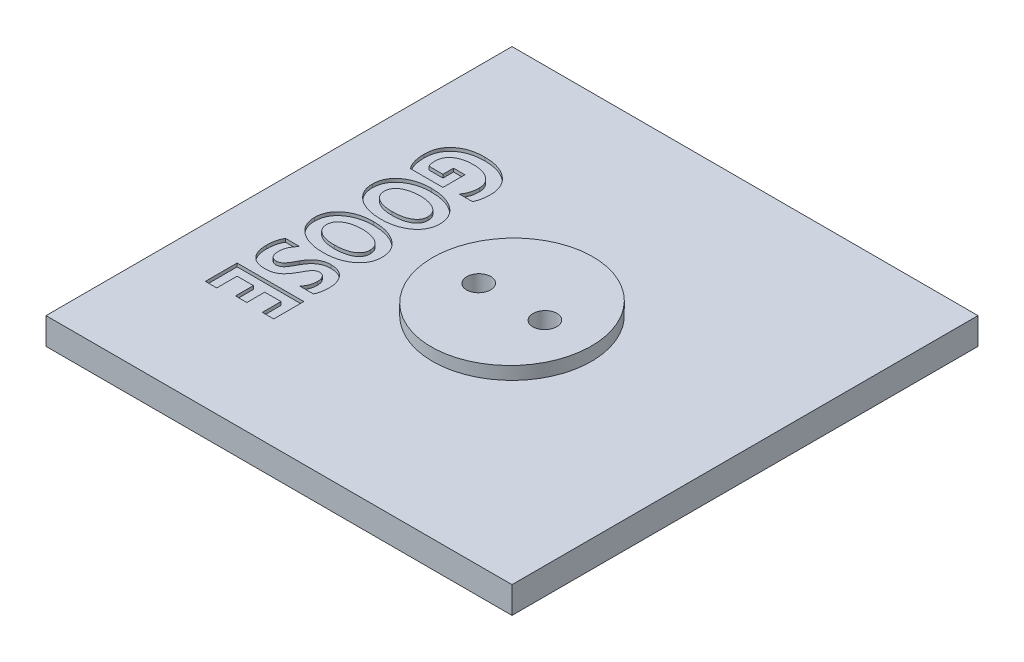
from build123d import *

# Parameters (mm, degrees)
SKETCH1_W           = 69.85
SKETCH1_H           = 69.85
BOSS_EXTRUDE1_DEPTH = 4
SKETCH2_R           = 11.90625
BOSS_EXTRUDE2_DEPTH = 2
CUT_EXTRUDE2_DEPTH  = 70.85
CUT_EXTRUDE1_REACH  = 8.401
SKETCH3_R           = 1.7859375
CUT_EXTRUDE3_DEPTH  = 0.5


with BuildPart() as part:
    # Sketch1 → Boss-Extrude1 (new body)
    with BuildSketch(Plane(origin=(0, 0, 0), x_dir=(1, 0, 0), z_dir=(0, 1, 0))):
        with Locations((34.925, 34.925)):
            Rectangle(SKETCH1_W, SKETCH1_H)
    extrude(amount=BOSS_EXTRUDE1_DEPTH)

    # Sketch2 → Boss-Extrude2 (add)
    with BuildSketch(Plane(origin=(0, 4, 0), x_dir=(1, 0, 0), z_dir=(0, 1, 0))):
        with Locations((34.925, 34.925)):
            Circle(SKETCH2_R)
    extrude(amount=BOSS_EXTRUDE2_DEPTH)

    # Sketch4 → Cut-Extrude2 (cut, through all)
    with BuildSketch(Plane(origin=(0, 0, 0), x_dir=(-1, 0, 0), z_dir=(0, 0, -1))):
        Polygon((-46.83125, 6), (-23.01875, 6), (-23.01875, 5.584351266), align=None)
    extrude(amount=CUT_EXTRUDE2_DEPTH, mode=Mode.SUBTRACT)

    # Cut-Extrude1: up to this face of the body (flat: up to its plane)
    cut_extrude1_end = Plane(part.part.faces().sort_by_distance((34.925, 0, -34.925))[0])
    # Sketch3 → Cut-Extrude1 (cut, up to the picked face)
    with BuildSketch(Plane(origin=(0.007132626, 5.182681991, 0), x_dir=(0.999847695, 0.017452406, 0), z_dir=(-0.017452406, 0.999847695, 0)), mode=Mode.PRIVATE) as cut_extrude1_sk1:
        with Locations((29.930971067, 34.925)):
            Circle(SKETCH3_R)
    cut_extrude1_tool1 = split(extrude(cut_extrude1_sk1.sketch, amount=-CUT_EXTRUDE1_REACH, mode=Mode.PRIVATE), bisect_by=cut_extrude1_end, keep=Keep.BOTH, mode=Mode.PRIVATE)
    add(cut_extrude1_tool1.solids().sort_by_distance((29.933545, 5.705049, -34.925))[0], mode=Mode.SUBTRACT)
    # Sketch3 → Cut-Extrude1 (cut, up to the picked face)
    with BuildSketch(Plane(origin=(0.007132626, 5.182681991, 0), x_dir=(0.999847695, 0.017452406, 0), z_dir=(-0.017452406, 0.999847695, 0)), mode=Mode.PRIVATE) as cut_extrude1_sk2:
        with Locations((39.852846067, 34.925)):
            Circle(SKETCH3_R)
    cut_extrude1_tool2 = split(extrude(cut_extrude1_sk2.sketch, amount=-CUT_EXTRUDE1_REACH, mode=Mode.PRIVATE), bisect_by=cut_extrude1_end, keep=Keep.BOTH, mode=Mode.PRIVATE)
    add(cut_extrude1_tool2.solids().sort_by_distance((39.853909, 5.87821, -34.925))[0], mode=Mode.SUBTRACT)

    # Sketch6 → Cut-Extrude3 (cut)
    with BuildSketch(Plane(origin=(0, 4, 0), x_dir=(1, 0, 0), z_dir=(0, 1, 0))):
        with BuildLine():
            add(Edge.make_bspline(
                [(8.210746951, 46.388414634), (8.144274713, 46.489009703), (8.011200203, 46.690396625), (7.841032576, 47.012884002), (7.698639266, 47.353240837), (7.580207721, 47.709835183), (7.488636108, 48.083234812), (7.424176489, 48.473706042), (7.385953722, 48.881296199), (7.380712454, 49.158912255), (7.37804878, 49.3)],
                knots=[0, 0, 0, 0, 0.000361561, 0.000723829, 0.001091884, 0.001467285, 0.001849947, 0.002244028, 0.002653579, 0.003076808, 0.003076808, 0.003076808, 0.003076808], degree=3))
            add(Edge.make_bspline(
                [(7.37804878, 49.3), (7.381808754, 49.456488516), (7.389161953, 49.762525597), (7.454413518, 50.208498087), (7.55528239, 50.631029508), (7.703518672, 51.026808603), (7.890305447, 51.398097163), (8.122427688, 51.741041446), (8.391620784, 52.062184966), (8.705379376, 52.352601314), (9.053983543, 52.612895229), (9.434039299, 52.841707584), (9.845263352, 53.033239566), (10.28622121, 53.192605453), (10.758494505, 53.313963145), (11.26100657, 53.39727702), (11.793078545, 53.453204269), (12.158131513, 53.458741135), (12.345655488, 53.461585366)],
                knots=[0, 0, 0, 0, 0.000469218, 0.000917628, 0.001349279, 0.00177012, 0.002182573, 0.002593209, 0.003009679, 0.003437057, 0.003872652, 0.004312836, 0.004765468, 0.005231394, 0.005717592, 0.006226018, 0.006758424, 0.007320805, 0.007320805, 0.007320805, 0.007320805], degree=3))
            add(Edge.make_bspline(
                [(12.345655488, 53.461585366), (12.536357719, 53.458103208), (12.909758722, 53.451285031), (13.455645242, 53.392791786), (13.974907069, 53.299202649), (14.465803229, 53.162466388), (14.931549548, 52.992677866), (15.367421121, 52.778871941), (15.778366641, 52.530916376), (16.157343495, 52.244444224), (16.500335529, 51.926722307), (16.80235491, 51.58341647), (17.054408646, 51.212268256), (17.265531017, 50.819446334), (17.424878767, 50.399400847), (17.539088757, 49.95661113), (17.60967499, 49.489635013), (17.617796553, 49.17004457), (17.62195122, 49.006554878)],
                knots=[0, 0, 0, 0, 0.000571964, 0.001119923, 0.001645026, 0.002153081, 0.002646852, 0.003130054, 0.003607172, 0.00408469, 0.00455256, 0.005007684, 0.005453231, 0.00589564, 0.006342586, 0.006797359, 0.007265446, 0.00775569, 0.00775569, 0.00775569, 0.00775569], degree=3))
            add(Edge.make_bspline(
                [(17.62195122, 49.006554878), (17.620405082, 48.900446847), (17.617365309, 48.691833966), (17.595825574, 48.384088133), (17.561926351, 48.08709295), (17.514602672, 47.800049122), (17.452036053, 47.523101535), (17.372918903, 47.257231798), (17.284972742, 46.99965161), (17.212217044, 46.835720432), (17.176067073, 46.754268293)],
                knots=[0, 0, 0, 0, 0.000318308, 0.000625806, 0.000925035, 0.001214801, 0.001498161, 0.001776134, 0.00204672, 0.002313937, 0.002313937, 0.002313937, 0.002313937], degree=3))
            Line((17.176067073, 46.754268293), (15.182926829, 46.754268293))
            add(Edge.make_bspline(
                [(15.182926829, 46.754268293), (15.241573527, 46.833293826), (15.358291723, 46.990569821), (15.506885605, 47.244281145), (15.63386436, 47.510506838), (15.735607243, 47.790341472), (15.816892855, 48.082624461), (15.873125571, 48.388057029), (15.908323164, 48.706566466), (15.912509469, 48.923255468), (15.914634146, 49.033231707)],
                knots=[0, 0, 0, 0, 0.000295049, 0.000587205, 0.000880408, 0.001178817, 0.001479304, 0.001789495, 0.002109555, 0.002439402, 0.002439402, 0.002439402, 0.002439402], degree=3))
            add(Edge.make_bspline(
                [(15.914634146, 49.033231707), (15.911682042, 49.128042132), (15.905903483, 49.313627555), (15.861195101, 49.584980778), (15.78680917, 49.842345893), (15.681139798, 50.086305871), (15.544946936, 50.315751088), (15.3792424, 50.531302602), (15.183245811, 50.731540038), (14.960261651, 50.917552078), (14.714198963, 51.086930916), (14.444997259, 51.231606471), (14.15851898, 51.355067801), (13.853955311, 51.459562909), (13.528915654, 51.536498736), (13.185500713, 51.590569064), (12.823413574, 51.626378353), (12.575673199, 51.630303162), (12.448551829, 51.632317073)],
                knots=[0, 0, 0, 0, 0.000284327, 0.000556551, 0.000822481, 0.001086197, 0.001351881, 0.001620953, 0.001899891, 0.002190707, 0.002490911, 0.002794452, 0.003105957, 0.003425926, 0.003759147, 0.004106557, 0.004468324, 0.004849593, 0.004849593, 0.004849593, 0.004849593], degree=3))
            add(Edge.make_bspline(
                [(12.448551829, 51.632317073), (12.319549339, 51.630743019), (12.068781924, 51.62768322), (11.704077879, 51.596735091), (11.361405332, 51.546097873), (11.040616977, 51.473313979), (10.740436623, 51.383102722), (10.462252183, 51.270215197), (10.206447121, 51.1367831), (9.972483353, 50.984724458), (9.765357339, 50.812797401), (9.582059575, 50.627858348), (9.428163778, 50.426220841), (9.303471957, 50.208726082), (9.205732081, 49.976378466), (9.135065316, 49.728969261), (9.092265748, 49.466634068), (9.087694978, 49.286823922), (9.085365854, 49.195198171)],
                knots=[0, 0, 0, 0, 0.000386931, 0.000752154, 0.001097095, 0.001425304, 0.001738135, 0.002036427, 0.002324503, 0.002602495, 0.002871844, 0.003130555, 0.003382087, 0.003630488, 0.003880696, 0.004136415, 0.004400811, 0.004675525, 0.004675525, 0.004675525, 0.004675525], degree=3))
            add(Edge.make_bspline(
                [(9.085365854, 49.195198171), (9.087999983, 49.088287378), (9.093059639, 48.88293235), (9.139311658, 48.590707285), (9.212384429, 48.326654756), (9.29120166, 48.170938519), (9.329268293, 48.095731707)],
                knots=[0, 0, 0, 0, 0.000320485, 0.000615589, 0.000885712, 0.001138043, 0.001138043, 0.001138043, 0.001138043], degree=3))
            Line((9.329268293, 48.095731707), (11.402439024, 48.095731707))
            Line((11.402439024, 48.095731707), (11.402439024, 49.681097561))
            Line((11.402439024, 49.681097561), (13.109756098, 49.681097561))
            Line((13.109756098, 49.681097561), (13.109756098, 46.388414634))
            Line((13.109756098, 46.388414634), (8.210746951, 46.388414634))
        make_face()
        with BuildLine():
            add(Edge.make_bspline(
                [(12.372332317, 45.412804878), (12.561732286, 45.409664284), (12.932365492, 45.403518514), (13.474839556, 45.351013526), (13.990806584, 45.266163524), (14.479787963, 45.146686602), (14.941394312, 44.992045512), (15.375888198, 44.803152073), (15.783581343, 44.579432253), (16.161785635, 44.323550537), (16.503719041, 44.039322137), (16.804593499, 43.732011315), (17.055311036, 43.399135346), (17.264471982, 43.046072718), (17.424158197, 42.668839076), (17.539201735, 42.270456116), (17.609526072, 41.850127955), (17.6177528, 41.56208898), (17.62195122, 41.415091463)],
                knots=[0, 0, 0, 0, 0.000568094, 0.001111693, 0.001633271, 0.00213563, 0.002620097, 0.003091989, 0.003555057, 0.004013271, 0.004459741, 0.004886914, 0.00530041, 0.005706954, 0.006115035, 0.006525706, 0.006948609, 0.00738937, 0.00738937, 0.00738937, 0.00738937], degree=3))
            add(Edge.make_bspline(
                [(17.62195122, 41.415091463), (17.617441063, 41.27510688), (17.608616579, 41.00121578), (17.542726642, 40.600464482), (17.43225414, 40.221572714), (17.276422151, 39.8627129), (17.074259472, 39.526631204), (16.831213805, 39.208986467), (16.539419441, 38.916937686), (16.209079549, 38.646257147), (15.845004655, 38.401327656), (15.451522909, 38.190094826), (15.034915449, 38.007273157), (14.59101181, 37.86172057), (14.122713754, 37.747468675), (13.629798374, 37.66570506), (13.111326414, 37.61824963), (12.757339147, 37.611420826), (12.576219512, 37.607926829)],
                knots=[0, 0, 0, 0, 0.00041983, 0.000821432, 0.001214573, 0.001601142, 0.001991656, 0.002388409, 0.002798023, 0.003227181, 0.003667942, 0.004112154, 0.004565279, 0.005031065, 0.005511705, 0.006010102, 0.006528682, 0.007072017, 0.007072017, 0.007072017, 0.007072017], degree=3))
            add(Edge.make_bspline(
                [(12.576219512, 37.607926829), (12.38743924, 37.610973441), (12.018675967, 37.61692469), (11.479665903, 37.670523808), (10.967519251, 37.751519468), (10.48331696, 37.873527694), (10.02466363, 38.024058552), (9.594304747, 38.212486267), (9.189363315, 38.430760601), (8.817971546, 38.686159349), (8.479874069, 38.966387639), (8.185518019, 39.272087431), (7.93390375, 39.598085042), (7.731869668, 39.947451531), (7.570903985, 40.316417658), (7.459491178, 40.707306959), (7.390836414, 41.119225657), (7.382371652, 41.400844573), (7.37804878, 41.544664634)],
                knots=[0, 0, 0, 0, 0.00056619, 0.001105995, 0.001623502, 0.002120312, 0.002602367, 0.003070004, 0.0035279, 0.003980316, 0.004419955, 0.004843111, 0.005250903, 0.005652233, 0.006050809, 0.006455459, 0.006868651, 0.007299898, 0.007299898, 0.007299898, 0.007299898], degree=3))
            add(Edge.make_bspline(
                [(7.37804878, 41.544664634), (7.381571465, 41.684692223), (7.388498842, 41.960057155), (7.458130336, 42.362009138), (7.566258529, 42.744755177), (7.718986256, 43.106975365), (7.91866586, 43.447515008), (8.159610575, 43.76907129), (8.44608771, 44.069459327), (8.773492806, 44.34581543), (9.13432037, 44.595942619), (9.522406067, 44.816023282), (9.936392267, 45.001814602), (10.375831729, 45.150997066), (10.839358862, 45.270291654), (11.328237827, 45.352835085), (11.842188281, 45.403005049), (12.193099922, 45.409491728), (12.372332317, 45.412804878)],
                knots=[0, 0, 0, 0, 0.000419731, 0.000825403, 0.001219844, 0.001610915, 0.002001135, 0.002401287, 0.002813728, 0.003243625, 0.003684465, 0.004129036, 0.004580218, 0.005043612, 0.005519634, 0.006014591, 0.006529556, 0.007067177, 0.007067177, 0.007067177, 0.007067177], degree=3))
        make_face()
        with BuildLine():
            add(Edge.make_bspline(
                [(12.486661585, 43.583536585), (12.369125312, 43.581395486), (12.138873676, 43.577201107), (11.80145716, 43.553560811), (11.481102797, 43.508670661), (11.176313546, 43.451050865), (10.888631379, 43.372586402), (10.617040318, 43.27770531), (10.362318787, 43.164580339), (10.125072193, 43.036510058), (9.910484528, 42.893296835), (9.722292963, 42.735580945), (9.563861185, 42.563723562), (9.432149392, 42.380132577), (9.331898818, 42.181890005), (9.258863703, 41.971933945), (9.216590028, 41.747683445), (9.210452077, 41.594382108), (9.207317073, 41.516082317)],
                knots=[0, 0, 0, 0, 0.000352644, 0.000690824, 0.001013932, 0.001322609, 0.001620755, 0.001907618, 0.002184865, 0.002456014, 0.002715504, 0.002957531, 0.003190819, 0.003414987, 0.003633147, 0.003854905, 0.004079881, 0.004314752, 0.004314752, 0.004314752, 0.004314752], degree=3))
            add(Edge.make_bspline(
                [(9.207317073, 41.516082317), (9.209628523, 41.436493302), (9.21417426, 41.279972133), (9.257381592, 41.052580496), (9.326243261, 40.838623449), (9.422087765, 40.637924622), (9.54783571, 40.45234143), (9.699090961, 40.278834522), (9.881369811, 40.123069881), (10.086056141, 39.978136747), (10.316421663, 39.851505711), (10.565192283, 39.738969391), (10.833945328, 39.645743085), (11.120868224, 39.570512609), (11.426002008, 39.508386289), (11.750350248, 39.468906278), (12.092976038, 39.44004979), (12.327803715, 39.438164524), (12.448551829, 39.437195122)],
                knots=[0, 0, 0, 0, 0.000238559, 0.000469155, 0.00069151, 0.000911393, 0.001133887, 0.001362077, 0.001599767, 0.001851407, 0.002113292, 0.002387059, 0.002669695, 0.002965506, 0.003276422, 0.003603056, 0.00394518, 0.004307303, 0.004307303, 0.004307303, 0.004307303], degree=3))
            add(Edge.make_bspline(
                [(12.448551829, 39.437195122), (12.574357416, 39.43843158), (12.819241859, 39.440838385), (13.176080587, 39.465998295), (13.512722352, 39.507250251), (13.828859409, 39.566428607), (14.125337708, 39.639749794), (14.40129138, 39.731366826), (14.656671226, 39.839984728), (14.892555871, 39.9629347), (15.10287313, 40.103383725), (15.288939171, 40.255955477), (15.44456006, 40.424796254), (15.571590077, 40.607812315), (15.672129767, 40.80357757), (15.74294062, 41.01413208), (15.785735294, 41.238041969), (15.790340759, 41.392035331), (15.792682927, 41.47035061)],
                knots=[0, 0, 0, 0, 0.000377364, 0.00073455, 0.001072526, 0.001394305, 0.001698861, 0.001988094, 0.00226557, 0.002530659, 0.002784861, 0.003022978, 0.003250881, 0.003471301, 0.003689461, 0.003908799, 0.004135648, 0.004370402, 0.004370402, 0.004370402, 0.004370402], degree=3))
            add(Edge.make_bspline(
                [(15.792682927, 41.47035061), (15.789585778, 41.550559104), (15.783544072, 41.707024305), (15.74107241, 41.93561855), (15.668119294, 42.150355769), (15.566117352, 42.352388446), (15.435110187, 42.540792896), (15.274468487, 42.71497533), (15.087390526, 42.87792427), (14.870513201, 43.022635401), (14.634140397, 43.155970861), (14.377159745, 43.269848852), (14.103834471, 43.366964297), (13.813601798, 43.44732333), (13.505765106, 43.507415151), (13.181257513, 43.550860104), (12.83963447, 43.577967575), (12.606123171, 43.581651787), (12.486661585, 43.583536585)],
                knots=[0, 0, 0, 0, 0.000240575, 0.000469297, 0.000694661, 0.00091878, 0.001146069, 0.001380762, 0.001627954, 0.001888512, 0.002161502, 0.002441265, 0.002730561, 0.003031048, 0.003343833, 0.003670717, 0.004012841, 0.0043712, 0.0043712, 0.0043712, 0.0043712], degree=3))
        make_face(mode=Mode.SUBTRACT)
        with BuildLine():
            add(Edge.make_bspline(
                [(12.372332317, 36.754268293), (12.561732286, 36.751127698), (12.932365492, 36.744981929), (13.474839556, 36.692476941), (13.990806584, 36.607626938), (14.479787963, 36.488150017), (14.941394312, 36.333508926), (15.375888198, 36.144615488), (15.783581343, 35.920895668), (16.161785635, 35.665013952), (16.503719041, 35.380785552), (16.804593499, 35.07347473), (17.055311036, 34.740598761), (17.264471982, 34.387536133), (17.424158197, 34.010302491), (17.539201735, 33.611919531), (17.609526072, 33.19159137), (17.6177528, 32.903552395), (17.62195122, 32.756554878)],
                knots=[0, 0, 0, 0, 0.000568094, 0.001111693, 0.001633271, 0.00213563, 0.002620097, 0.003091989, 0.003555057, 0.004013271, 0.004459741, 0.004886914, 0.00530041, 0.005706954, 0.006115035, 0.006525706, 0.006948609, 0.00738937, 0.00738937, 0.00738937, 0.00738937], degree=3))
            add(Edge.make_bspline(
                [(17.62195122, 32.756554878), (17.617441063, 32.616570294), (17.608616579, 32.342679195), (17.542726642, 31.941927896), (17.43225414, 31.563036129), (17.276422151, 31.204176314), (17.074259472, 30.868094618), (16.831213805, 30.550449881), (16.539419441, 30.258401101), (16.209079549, 29.987720562), (15.845004655, 29.74279107), (15.451522909, 29.53155824), (15.034915449, 29.348736572), (14.59101181, 29.203183985), (14.122713754, 29.088932089), (13.629798374, 29.007168474), (13.111326414, 28.959713045), (12.757339147, 28.952884241), (12.576219512, 28.949390244)],
                knots=[0, 0, 0, 0, 0.00041983, 0.000821432, 0.001214573, 0.001601142, 0.001991656, 0.002388409, 0.002798023, 0.003227181, 0.003667942, 0.004112154, 0.004565279, 0.005031065, 0.005511705, 0.006010102, 0.006528682, 0.007072017, 0.007072017, 0.007072017, 0.007072017], degree=3))
            add(Edge.make_bspline(
                [(12.576219512, 28.949390244), (12.38743924, 28.952436856), (12.018675967, 28.958388105), (11.479665903, 29.011987223), (10.967519251, 29.092982883), (10.48331696, 29.214991108), (10.02466363, 29.365521967), (9.594304747, 29.553949681), (9.189363315, 29.772224016), (8.817971546, 30.027622764), (8.479874069, 30.307851053), (8.185518019, 30.613550846), (7.93390375, 30.939548456), (7.731869668, 31.288914946), (7.570903985, 31.657881072), (7.459491178, 32.048770373), (7.390836414, 32.460689071), (7.382371652, 32.742307988), (7.37804878, 32.886128049)],
                knots=[0, 0, 0, 0, 0.00056619, 0.001105995, 0.001623502, 0.002120312, 0.002602367, 0.003070004, 0.0035279, 0.003980316, 0.004419955, 0.004843111, 0.005250903, 0.005652233, 0.006050809, 0.006455459, 0.006868651, 0.007299898, 0.007299898, 0.007299898, 0.007299898], degree=3))
            add(Edge.make_bspline(
                [(7.37804878, 32.886128049), (7.381571465, 33.026155638), (7.388498842, 33.30152057), (7.458130336, 33.703472552), (7.566258529, 34.086218591), (7.718986256, 34.44843878), (7.91866586, 34.788978422), (8.159610575, 35.110534704), (8.44608771, 35.410922742), (8.773492806, 35.687278845), (9.13432037, 35.937406033), (9.522406067, 36.157486697), (9.936392267, 36.343278016), (10.375831729, 36.492460481), (10.839358862, 36.611755068), (11.328237827, 36.6942985), (11.842188281, 36.744468464), (12.193099922, 36.750955143), (12.372332317, 36.754268293)],
                knots=[0, 0, 0, 0, 0.000419731, 0.000825403, 0.001219844, 0.001610915, 0.002001135, 0.002401287, 0.002813728, 0.003243625, 0.003684465, 0.004129036, 0.004580218, 0.005043612, 0.005519634, 0.006014591, 0.006529556, 0.007067177, 0.007067177, 0.007067177, 0.007067177], degree=3))
        make_face()
        with BuildLine():
            add(Edge.make_bspline(
                [(12.486661585, 34.925), (12.369125312, 34.9228589), (12.138873676, 34.918664521), (11.80145716, 34.895024226), (11.481102797, 34.850134076), (11.176313546, 34.79251428), (10.888631379, 34.714049817), (10.617040318, 34.619168725), (10.362318787, 34.506043753), (10.125072193, 34.377973472), (9.910484528, 34.23476025), (9.722292963, 34.07704436), (9.563861185, 33.905186977), (9.432149392, 33.721595992), (9.331898818, 33.523353419), (9.258863703, 33.313397359), (9.216590028, 33.08914686), (9.210452077, 32.935845522), (9.207317073, 32.857545732)],
                knots=[0, 0, 0, 0, 0.000352644, 0.000690824, 0.001013932, 0.001322609, 0.001620755, 0.001907618, 0.002184865, 0.002456014, 0.002715504, 0.002957531, 0.003190819, 0.003414987, 0.003633147, 0.003854905, 0.004079881, 0.004314752, 0.004314752, 0.004314752, 0.004314752], degree=3))
            add(Edge.make_bspline(
                [(9.207317073, 32.857545732), (9.209628523, 32.777956717), (9.21417426, 32.621435548), (9.257381592, 32.39404391), (9.326243261, 32.180086864), (9.422087765, 31.979388037), (9.54783571, 31.793804845), (9.699090961, 31.620297936), (9.881369811, 31.464533296), (10.086056141, 31.319600162), (10.316421663, 31.192969125), (10.565192283, 31.080432805), (10.833945328, 30.9872065), (11.120868224, 30.911976024), (11.426002008, 30.849849704), (11.750350248, 30.810369692), (12.092976038, 30.781513205), (12.327803715, 30.779627938), (12.448551829, 30.778658537)],
                knots=[0, 0, 0, 0, 0.000238559, 0.000469155, 0.00069151, 0.000911393, 0.001133887, 0.001362077, 0.001599767, 0.001851407, 0.002113292, 0.002387059, 0.002669695, 0.002965506, 0.003276422, 0.003603056, 0.00394518, 0.004307303, 0.004307303, 0.004307303, 0.004307303], degree=3))
            add(Edge.make_bspline(
                [(12.448551829, 30.778658537), (12.574357416, 30.779894995), (12.819241859, 30.782301799), (13.176080587, 30.80746171), (13.512722352, 30.848713665), (13.828859409, 30.907892022), (14.125337708, 30.981213209), (14.40129138, 31.072830241), (14.656671226, 31.181448142), (14.892555871, 31.304398115), (15.10287313, 31.444847139), (15.288939171, 31.597418892), (15.44456006, 31.766259669), (15.571590077, 31.949275729), (15.672129767, 32.145040985), (15.74294062, 32.355595495), (15.785735294, 32.579505383), (15.790340759, 32.733498745), (15.792682927, 32.811814024)],
                knots=[0, 0, 0, 0, 0.000377364, 0.00073455, 0.001072526, 0.001394305, 0.001698861, 0.001988094, 0.00226557, 0.002530659, 0.002784861, 0.003022978, 0.003250881, 0.003471301, 0.003689461, 0.003908799, 0.004135648, 0.004370402, 0.004370402, 0.004370402, 0.004370402], degree=3))
            add(Edge.make_bspline(
                [(15.792682927, 32.811814024), (15.789585778, 32.892022518), (15.783544072, 33.04848772), (15.74107241, 33.277081965), (15.668119294, 33.491819184), (15.566117352, 33.69385186), (15.435110187, 33.882256311), (15.274468487, 34.056438744), (15.087390526, 34.219387685), (14.870513201, 34.364098815), (14.634140397, 34.497434275), (14.377159745, 34.611312267), (14.103834471, 34.708427712), (13.813601798, 34.788786744), (13.505765106, 34.848878566), (13.181257513, 34.892323519), (12.83963447, 34.919430989), (12.606123171, 34.923115201), (12.486661585, 34.925)],
                knots=[0, 0, 0, 0, 0.000240575, 0.000469297, 0.000694661, 0.00091878, 0.001146069, 0.001380762, 0.001627954, 0.001888512, 0.002161502, 0.002441265, 0.002730561, 0.003031048, 0.003343833, 0.003670717, 0.004012841, 0.0043712, 0.0043712, 0.0043712, 0.0043712], degree=3))
        make_face(mode=Mode.SUBTRACT)
        with BuildLine():
            add(Edge.make_bspline(
                [(10.06097561, 27.973780488), (9.983145547, 27.891977285), (9.830309704, 27.73133934), (9.632492804, 27.470633528), (9.463381892, 27.203211357), (9.324811357, 26.927077004), (9.217704216, 26.642139657), (9.141425585, 26.349046012), (9.093853854, 26.047618124), (9.08821494, 25.843619834), (9.085365854, 25.74054878)],
                knots=[0, 0, 0, 0, 0.000338518, 0.000664752, 0.000979843, 0.001286621, 0.001589929, 0.001891267, 0.002193904, 0.002502969, 0.002502969, 0.002502969, 0.002502969], degree=3))
            add(Edge.make_bspline(
                [(9.085365854, 25.74054878), (9.0856863, 25.683336574), (9.086310653, 25.571865221), (9.102965507, 25.410399347), (9.12462095, 25.259271005), (9.157067784, 25.119673048), (9.198458963, 24.99114791), (9.251032082, 24.874512826), (9.308862332, 24.766122855), (9.402258563, 24.642290481), (9.534344119, 24.51096071), (9.720891494, 24.397130652), (9.929214864, 24.327946245), (10.075692695, 24.31953931), (10.150533537, 24.315243902)],
                knots=[0, 0, 0, 0, 0.000171536, 0.000334218, 0.000486479, 0.000629301, 0.000763675, 0.000890787, 0.001012753, 0.001131277, 0.001354959, 0.001567051, 0.001781569, 0.00200568, 0.00200568, 0.00200568, 0.00200568], degree=3))
            add(Edge.make_bspline(
                [(10.150533537, 24.315243902), (10.21760376, 24.318302854), (10.35137784, 24.324404049), (10.547770946, 24.381861978), (10.737296395, 24.471068735), (10.893747216, 24.571917884), (11.015295577, 24.68594369), (11.118921535, 24.799093241), (11.228068111, 24.94301287), (11.346031261, 25.114868014), (11.471294931, 25.315460356), (11.605032964, 25.544696562), (11.744615287, 25.803784706), (11.840255949, 25.986258547), (11.890243902, 26.081631098)],
                knots=[0, 0, 0, 0, 0.00020081, 0.000400523, 0.000608535, 0.000828386, 0.000955155, 0.001107558, 0.001288218, 0.001496466, 0.001732785, 0.001997504, 0.002292528, 0.002615569, 0.002615569, 0.002615569, 0.002615569], degree=3))
            add(Edge.make_bspline(
                [(11.890243902, 26.081631098), (11.931348606, 26.158314244), (12.01234913, 26.309425295), (12.145468391, 26.523737919), (12.285239748, 26.723671701), (12.432458753, 26.90804968), (12.583581881, 27.080722789), (12.745451094, 27.235349554), (12.912666523, 27.377131146), (13.088288616, 27.502666036), (13.269663196, 27.613732489), (13.458261322, 27.709857706), (13.65377821, 27.791526084), (13.856374312, 27.858271639), (14.065842313, 27.910558476), (14.282036063, 27.945155778), (14.505281346, 27.969838497), (14.656306367, 27.972450203), (14.733231707, 27.973780488)],
                knots=[0, 0, 0, 0, 0.000260961, 0.000514248, 0.000756365, 0.000992353, 0.001221804, 0.001444159, 0.001663249, 0.001878999, 0.002091091, 0.002300729, 0.002513411, 0.002726118, 0.002940094, 0.003160316, 0.003382532, 0.003613222, 0.003613222, 0.003613222, 0.003613222], degree=3))
            add(Edge.make_bspline(
                [(14.733231707, 27.973780488), (14.844517391, 27.971378181), (15.061491464, 27.966694394), (15.377224123, 27.925676845), (15.674646125, 27.860330511), (15.95143696, 27.764218709), (16.210439075, 27.643778586), (16.448566322, 27.49462911), (16.668803232, 27.31913796), (16.867580278, 27.117693787), (17.044659792, 26.893984505), (17.200338059, 26.65237239), (17.331406478, 26.392975258), (17.439295266, 26.116210875), (17.520281403, 25.821575973), (17.578831928, 25.509939566), (17.616296245, 25.1812469), (17.620037867, 24.956226957), (17.62195122, 24.841158537)],
                knots=[0, 0, 0, 0, 0.000333727, 0.000650669, 0.000953455, 0.001245717, 0.001527864, 0.001808618, 0.002086565, 0.002370866, 0.002655658, 0.002941081, 0.003231672, 0.003526081, 0.003830751, 0.004146912, 0.00447665, 0.004821732, 0.004821732, 0.004821732, 0.004821732], degree=3))
            add(Edge.make_bspline(
                [(17.62195122, 24.841158537), (17.621070444, 24.744578699), (17.619341844, 24.555032144), (17.599364009, 24.276566383), (17.569132483, 24.009523962), (17.528282951, 23.754108684), (17.472208076, 23.511347656), (17.406155181, 23.27996729), (17.326406457, 23.060294105), (17.262727089, 22.920676142), (17.23132622, 22.851829268)],
                knots=[0, 0, 0, 0, 0.000289691, 0.000568544, 0.000837048, 0.001095802, 0.001344028, 0.001584044, 0.001817332, 0.002044277, 0.002044277, 0.002044277, 0.002044277], degree=3))
            Line((17.23132622, 22.851829268), (15.182926829, 22.851829268))
            add(Edge.make_bspline(
                [(15.182926829, 22.851829268), (15.241353304, 22.920064548), (15.356533103, 23.054581064), (15.505747627, 23.271635111), (15.631816919, 23.496904724), (15.735730854, 23.730844884), (15.815724238, 23.973487606), (15.873010159, 24.22480172), (15.908211065, 24.484466391), (15.912478028, 24.660662356), (15.914634146, 24.749695122)],
                knots=[0, 0, 0, 0, 0.000269349, 0.000530984, 0.000788613, 0.001042836, 0.001297724, 0.001553804, 0.001815211, 0.002082224, 0.002082224, 0.002082224, 0.002082224], degree=3))
            add(Edge.make_bspline(
                [(15.914634146, 24.749695122), (15.911585705, 24.850268644), (15.905752953, 25.042701553), (15.85527155, 25.315748118), (15.766959744, 25.55697134), (15.645062357, 25.763716045), (15.496019198, 25.934722658), (15.316170515, 26.056705983), (15.112638443, 26.13354977), (14.96766084, 26.140795436), (14.893292683, 26.144512195)],
                knots=[0, 0, 0, 0, 0.000301555, 0.000576982, 0.000828997, 0.00106821, 0.001293549, 0.001503369, 0.001714354, 0.00193657, 0.00193657, 0.00193657, 0.00193657], degree=3))
            add(Edge.make_bspline(
                [(14.893292683, 26.144512195), (14.832027515, 26.140953218), (14.710186392, 26.1338753), (14.530747654, 26.08435411), (14.360286583, 26.000236692), (14.222416662, 25.904933337), (14.115355285, 25.801205358), (14.026153567, 25.699968113), (13.930843178, 25.574650211), (13.828351669, 25.425562357), (13.717777339, 25.252417258), (13.602807364, 25.053659864), (13.478399414, 24.833226495), (13.396416015, 24.676887418), (13.353658537, 24.59535061)],
                knots=[0, 0, 0, 0, 0.000183729, 0.000365391, 0.000553736, 0.000751989, 0.000865201, 0.001000182, 0.001156443, 0.001337214, 0.001542839, 0.001772583, 0.002025955, 0.002302139, 0.002302139, 0.002302139, 0.002302139], degree=3))
            add(Edge.make_bspline(
                [(13.353658537, 24.59535061), (13.30128518, 24.498243402), (13.199361733, 24.3092637), (13.034990477, 24.04381217), (12.871512325, 23.799605454), (12.703523741, 23.580583257), (12.534719965, 23.383555929), (12.362383366, 23.210587965), (12.18787088, 23.061848116), (12.009305811, 22.935945815), (11.826910949, 22.828539471), (11.63728503, 22.736017235), (11.437607017, 22.660805425), (11.230669051, 22.595211061), (11.014611072, 22.545802004), (10.790358274, 22.51207408), (10.558088356, 22.490601499), (10.400199694, 22.487532261), (10.320121951, 22.48597561)],
                knots=[0, 0, 0, 0, 0.000330919, 0.000644, 0.000936261, 0.001212188, 0.001471573, 0.001714102, 0.001943932, 0.002158577, 0.002368708, 0.002578355, 0.002790678, 0.003008246, 0.003229192, 0.003454757, 0.00368817, 0.003928382, 0.003928382, 0.003928382, 0.003928382], degree=3))
            add(Edge.make_bspline(
                [(10.320121951, 22.48597561), (10.203776964, 22.488523256), (9.9780551, 22.493465965), (9.6496152, 22.532064284), (9.342319435, 22.595551018), (9.05649224, 22.687799408), (8.791345396, 22.803925325), (8.547516036, 22.94698248), (8.327143352, 23.119162398), (8.125757701, 23.313504383), (7.948601505, 23.533493061), (7.795204509, 23.77603413), (7.664855025, 24.040239435), (7.561451189, 24.327085643), (7.478822658, 24.634262223), (7.420907106, 24.963253782), (7.383625884, 25.314130535), (7.379940505, 25.555616926), (7.37804878, 25.679573171)],
                knots=[0, 0, 0, 0, 0.000348959, 0.000677019, 0.000990569, 0.001288855, 0.001576356, 0.001857401, 0.002134491, 0.002413429, 0.002695248, 0.002979644, 0.003272792, 0.003577224, 0.00389292, 0.004225944, 0.004578418, 0.004950164, 0.004950164, 0.004950164, 0.004950164], degree=3))
            add(Edge.make_bspline(
                [(7.37804878, 25.679573171), (7.380147969, 25.793940335), (7.384246371, 26.017227809), (7.408340013, 26.344430459), (7.452244311, 26.655601987), (7.513383274, 26.950709927), (7.588461891, 27.231042444), (7.684798042, 27.494261458), (7.795468955, 27.743313049), (7.886007998, 27.897682379), (7.930640244, 27.973780488)],
                knots=[0, 0, 0, 0, 0.00034312, 0.000669899, 0.00098357, 0.001285149, 0.001573603, 0.001853288, 0.002125319, 0.002389798, 0.002389798, 0.002389798, 0.002389798], degree=3))
            Line((7.930640244, 27.973780488), (10.06097561, 27.973780488))
        make_face()
        Polygon((7.5, 16.388414634), (7.5, 21.144512195), (17.5, 21.144512195), (17.5, 16.632317073), (15.792682927, 16.632317073), (15.792682927, 19.433384146), (13.353658537, 19.433384146), (13.353658537, 16.754268293), (11.646341463, 16.754268293), (11.646341463, 19.437195122), (9.207317073, 19.437195122), (9.207317073, 16.388414634), align=None)
    extrude(amount=-CUT_EXTRUDE3_DEPTH, mode=Mode.SUBTRACT)


solid = part.part
